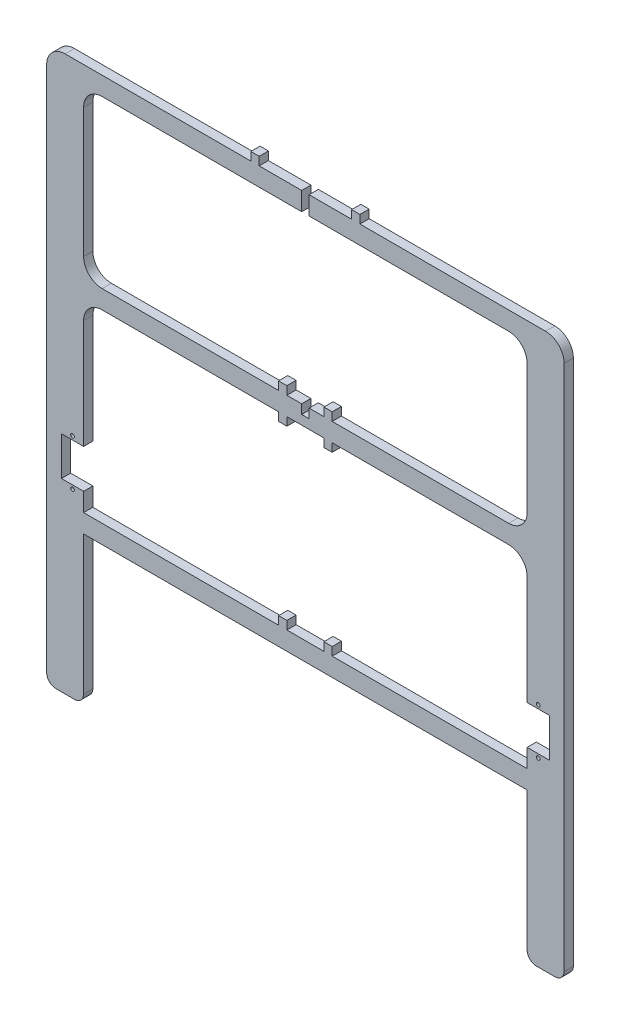
from build123d import *

# Parameters (mm, degrees)
SKETCH1_R           = 1
SKETCH1_W           = 4.5
SKETCH1_H           = 4.5
BOSS_EXTRUDE1_DEPTH = 2.5


with BuildPart() as part:
    # Sketch1 → Boss-Extrude1 (new body, symmetric)
    with BuildSketch(Plane.XY):
        with BuildLine():
            Line((-140, 90), (-140, -195))
            ThreePointArc((-140, -195), (-138.535533906, -198.535533906), (-135, -200))
            Line((-135, -200), (-125, -200))
            ThreePointArc((-125, -200), (-121.464466094, -198.535533906), (-120, -195))
            Line((-120, -195), (-120, -100))
            Line((-120, -100), (-132, -100))
            Line((-132, -100), (-132, -79))
            Line((-132, -79), (-120, -79))
            Line((-120, -79), (-120, -20))
            ThreePointArc((-120, -20), (-117.071067812, -12.928932188), (-110, -10))
            Line((-110, -10), (0, -10))
            Line((0, -10), (0, -5))
            Line((0, -5), (-2, -5))
            Line((-2, -5), (-2, 0))
            Line((-2, 0), (-110, 0))
            ThreePointArc((-110, 0), (-117.071067812, 2.928932188), (-120, 10))
            Line((-120, 10), (-120, 80))
            ThreePointArc((-120, 80), (-117.071067812, 87.071067812), (-110, 90))
            Line((-110, 90), (-2, 90))
            Line((-2, 90), (-2, 100))
            Line((-2, 100), (-120, 100))
            Line((-120, 100), (-130, 100))
            ThreePointArc((-130, 100), (-137.071067812, 97.071067812), (-140, 90))
        make_face()
        with Locations((-126, -77)):
            Circle(SKETCH1_R, mode=Mode.SUBTRACT)
        with Locations((-126, -102)):
            Circle(SKETCH1_R, mode=Mode.SUBTRACT)
        Polygon((-14.5, -110), (-120, -110), (-120, -120), (0, -120), (0, -110), (-10, -110), align=None)
        with Locations((-12.25, -107.75)):
            Rectangle(SKETCH1_W, SKETCH1_H)
        with Locations((-12.25, 2.25)):
            Rectangle(SKETCH1_W, SKETCH1_H)
        with Locations((-12.25, -12.25)):
            Rectangle(SKETCH1_W, SKETCH1_H)
        with Locations((-27.25, 102.25)):
            Rectangle(SKETCH1_W, SKETCH1_H)
    boss_extrude1 = extrude(amount=BOSS_EXTRUDE1_DEPTH, both=True)

    # Mirror1: Boss-Extrude1 across plane
    add(boss_extrude1.mirror(Plane(origin=(0, 0, 0), x_dir=(0, 0, 1), z_dir=(1, 0, 0))))


solid = part.part
